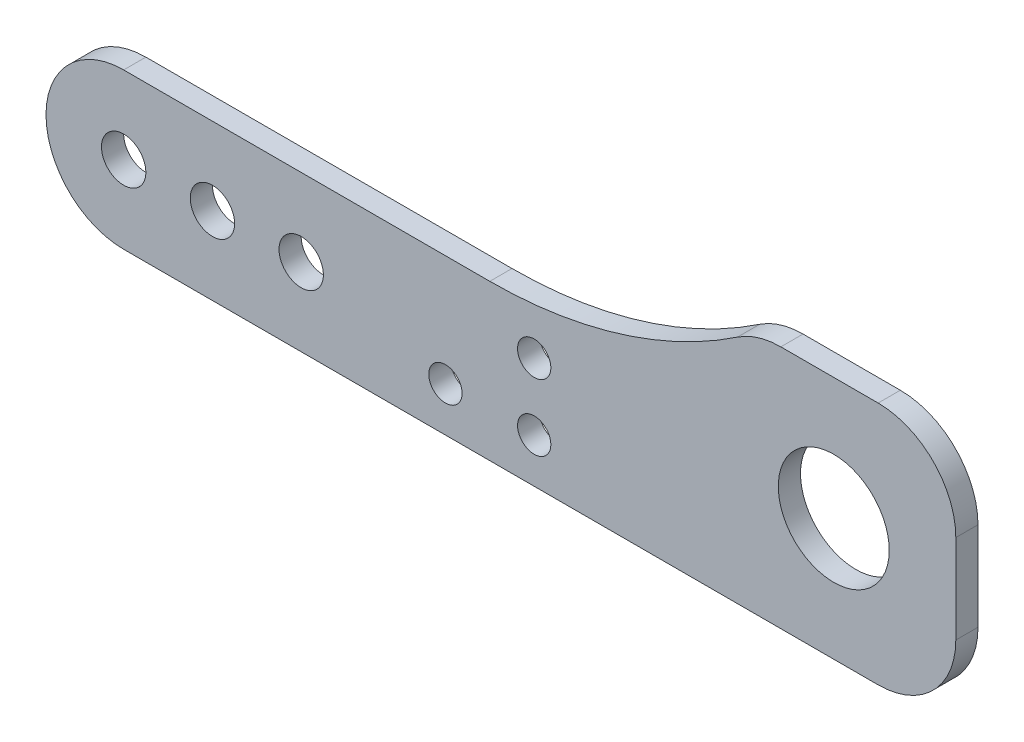
from build123d import *

# Parameters (mm, degrees)
BOSS_EXTRUDE1_DEPTH   = 2
SKETCH2_R             = 2
CUT_EXTRUDE1_DEPTH    = 2
SKETCH3_R             = 5
CUT_EXTRUDE2_DEPTH    = 2
F_3_0MM_DOWEL_HOLE2_D = 3


with BuildPart() as part:
    # Sketch1 → Boss-Extrude1 (new body)
    with BuildSketch(Plane.XY):
        with BuildLine():
            Line((0, 7), (33, 7))
            ThreePointArc((33, 7), (44.66919932, 8.739971416), (55.323194976, 13.808510638))
            ThreePointArc((55.323194976, 13.808510638), (57.187644216, 14.695505002), (59.229754097, 15))
            Line((59.229754097, 15), (68, 15))
            ThreePointArc((68, 15), (72.949747468, 12.949747468), (75, 8))
            Line((75, 8), (75, 0))
            ThreePointArc((75, 0), (72.949747468, -4.949747468), (68, -7))
            Line((68, -7), (0, -7))
            ThreePointArc((0, -7), (-7, 0), (0, 7))
        make_face()
    extrude(amount=BOSS_EXTRUDE1_DEPTH)

    # Sketch2 → Cut-Extrude1 (cut)
    with BuildSketch(Plane.XY.offset(2)):
        Circle(SKETCH2_R)
        with Locations((8, 0)):
            Circle(SKETCH2_R)
        with Locations((16, 0)):
            Circle(SKETCH2_R)
    extrude(amount=-CUT_EXTRUDE1_DEPTH, mode=Mode.SUBTRACT)

    # Sketch3 → Cut-Extrude2 (cut)
    with BuildSketch(Plane.XY.offset(2)):
        with Locations((64, 4)):
            Circle(SKETCH3_R)
    extrude(amount=-CUT_EXTRUDE2_DEPTH, mode=Mode.SUBTRACT)

    # Ø3.0mm Dowel Hole2 (through all)
    with Locations(Plane.XY.offset(2)):
        with Locations((29, -3), (37, -3), (37, 3)):
            Hole(F_3_0MM_DOWEL_HOLE2_D / 2)


solid = part.part
